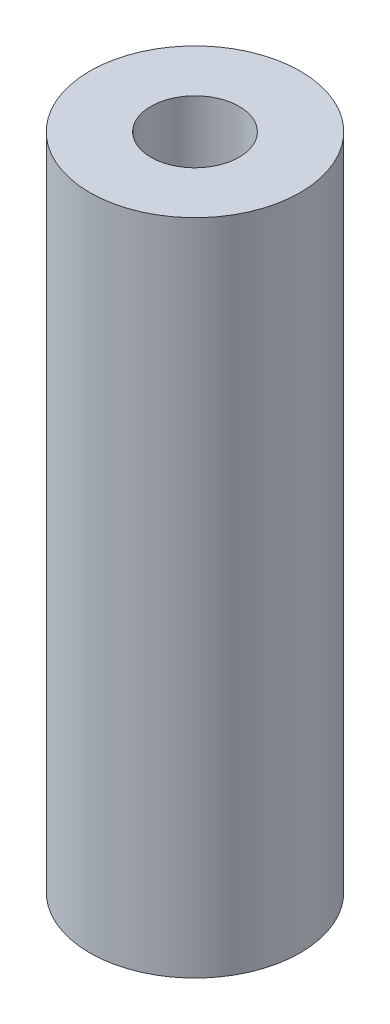
from build123d import *

# Parameters (mm, degrees)
SKETCH1_R           = 15.5
SKETCH1_R_2         = 6.5
BOSS_EXTRUDE1_DEPTH = 48.5


with BuildPart() as part:
    # Sketch1 → Boss-Extrude1 (new body, symmetric)
    with BuildSketch(Plane(origin=(0, 0, 0), x_dir=(1, 0, 0), z_dir=(0, 1, 0))):
        Circle(SKETCH1_R)
        Circle(SKETCH1_R_2, mode=Mode.SUBTRACT)
    extrude(amount=BOSS_EXTRUDE1_DEPTH, both=True)


solid = part.part
